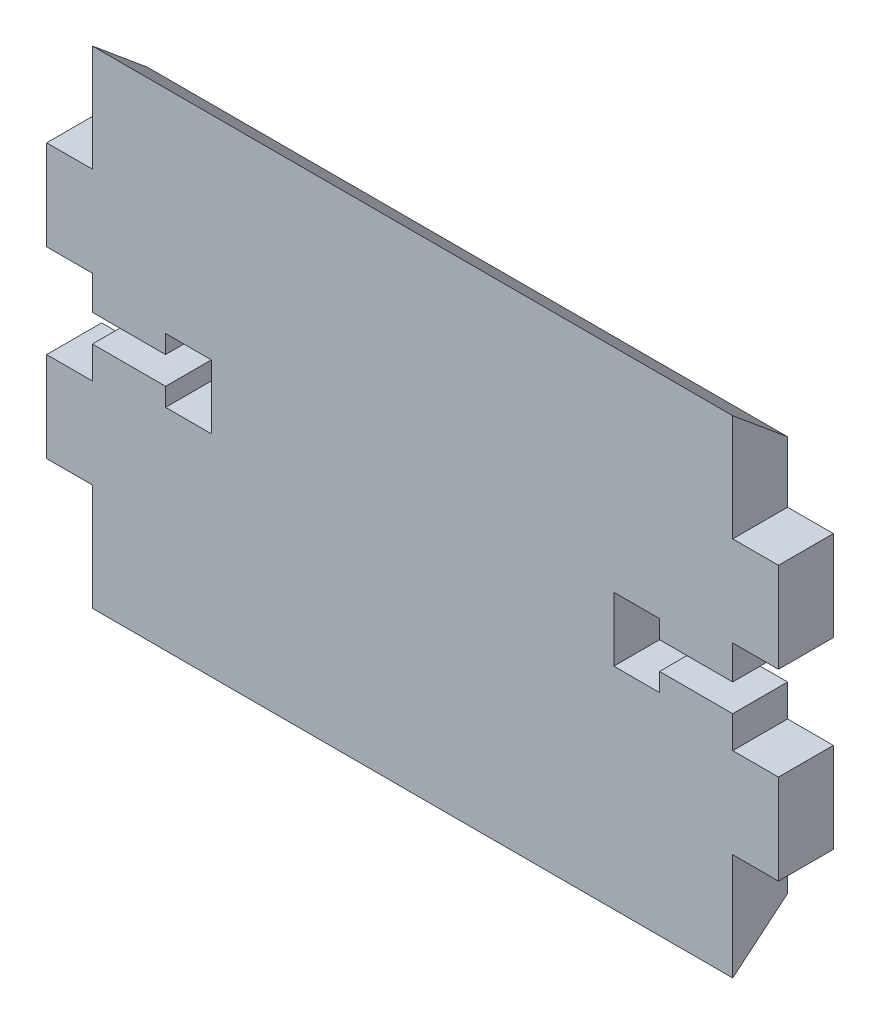
from build123d import *

# Parameters (mm, degrees)
RESSALTO_EXTRUS_O1_DEPTH = 6
CORTE_EXTRUS_O2_DEPTH    = 76


with BuildPart() as part:
    # Model → Ressalto-extrusão1 (new body)
    with BuildSketch(Plane.XY):
        Polygon((35, -42.315), (35, -54.735), (-35, -54.735), (-35, -42.315), (-40, -42.315), (-40, -32.465), (-35, -32.465), (-35, -28.965000001), (-27, -28.965000001), (-27, -30.965000001), (-22, -30.965000001), (-22, -23.965000001), (-27, -23.965000001), (-27, -25.965000001), (-35, -25.965000001), (-35, -22.265), (-40, -22.265), (-40, -12.415), (-35, -12.415), (-35, 0), (35, 0), (35, -12.415), (40, -12.415), (40, -22.265), (35, -22.265), (35, -25.965000001), (27, -25.965000001), (27, -23.965000001), (22, -23.965000001), (22, -30.965000001), (27, -30.965000001), (27, -28.965000001), (35, -28.965000001), (35, -32.465), (40, -32.465), (40, -42.315), align=None)
    extrude(amount=RESSALTO_EXTRUS_O1_DEPTH)

    # Esboço2 → Corte-extrusão2 (cut, through all)
    with BuildSketch(Plane(origin=(35, 0, 0), x_dir=(0, 0, -1), z_dir=(1, 0, 0))):
        Polygon((-6, -0.75), (0, -5.75), (0, 4.25), (-6, 4.25), align=None)
        Polygon((-6, -58.99), (-6, -53.99), (0, -48.99), (0, -58.99), align=None)
    extrude(amount=-CORTE_EXTRUS_O2_DEPTH, mode=Mode.SUBTRACT)


solid = part.part
